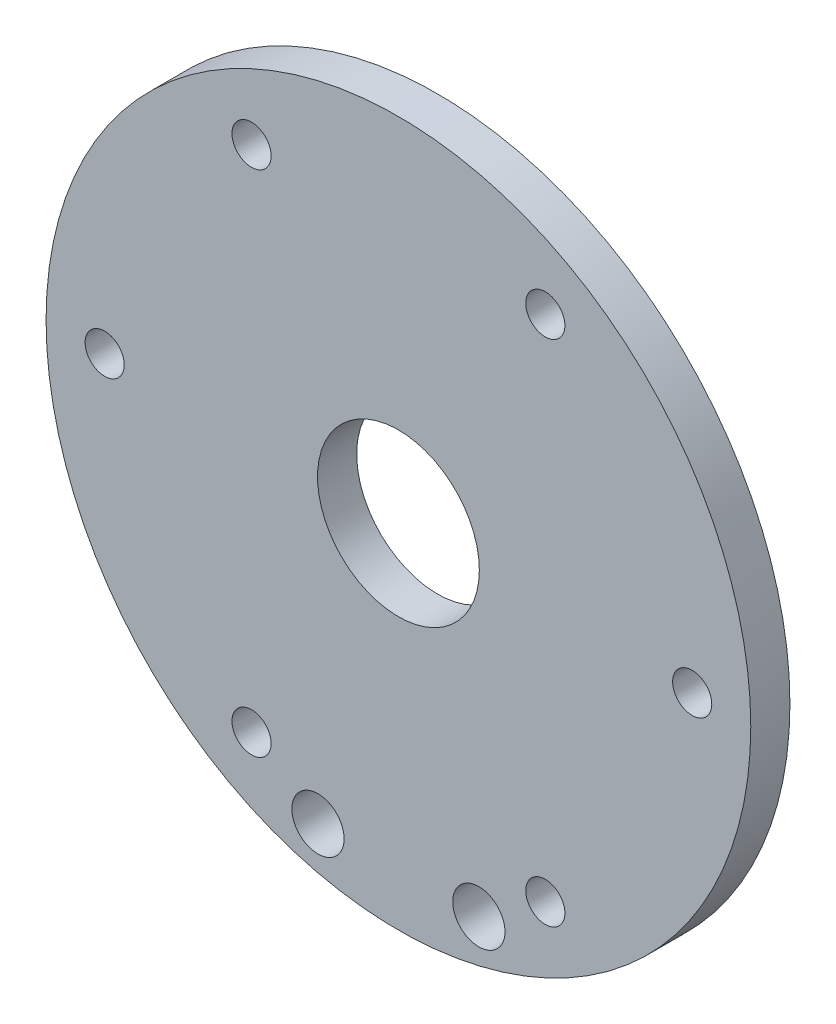
from build123d import *

# Parameters (mm, degrees)
SKETCH_1_R      = 27
SKETCH_1_R_2    = 6.2
SKETCH_1_R_3    = 2
SKETCH_1_R_4    = 1.5
EXTRUDE_1_DEPTH = 3


with BuildPart() as part:
    # 草图1 → 凸台-拉伸1 (new body)
    with BuildSketch(Plane.XY):
        with Locations((3146.417198556, 2145.903344986)):
            Circle(SKETCH_1_R)
        with Locations((3146.417198556, 2145.903344986)):
            Circle(SKETCH_1_R_2, mode=Mode.SUBTRACT)
        with Locations((3152.581001127, 2122.876849306)):
            Circle(SKETCH_1_R_3, mode=Mode.SUBTRACT)
        with Locations((3168.927561327, 2145.903344986)):
            Circle(SKETCH_1_R_4, mode=Mode.SUBTRACT)
        with Locations((3157.672379942, 2165.397890994)):
            Circle(SKETCH_1_R_4, mode=Mode.SUBTRACT)
        with Locations((3135.162017171, 2165.397890994)):
            Circle(SKETCH_1_R_4, mode=Mode.SUBTRACT)
        with Locations((3123.906835785, 2145.903344986)):
            Circle(SKETCH_1_R_4, mode=Mode.SUBTRACT)
        with Locations((3135.162017171, 2126.408798978)):
            Circle(SKETCH_1_R_4, mode=Mode.SUBTRACT)
        with Locations((3157.672379942, 2126.408798978)):
            Circle(SKETCH_1_R_4, mode=Mode.SUBTRACT)
        with Locations((3140.253395985, 2122.876849306)):
            Circle(SKETCH_1_R_3, mode=Mode.SUBTRACT)
    extrude(amount=EXTRUDE_1_DEPTH)


solid = part.part
